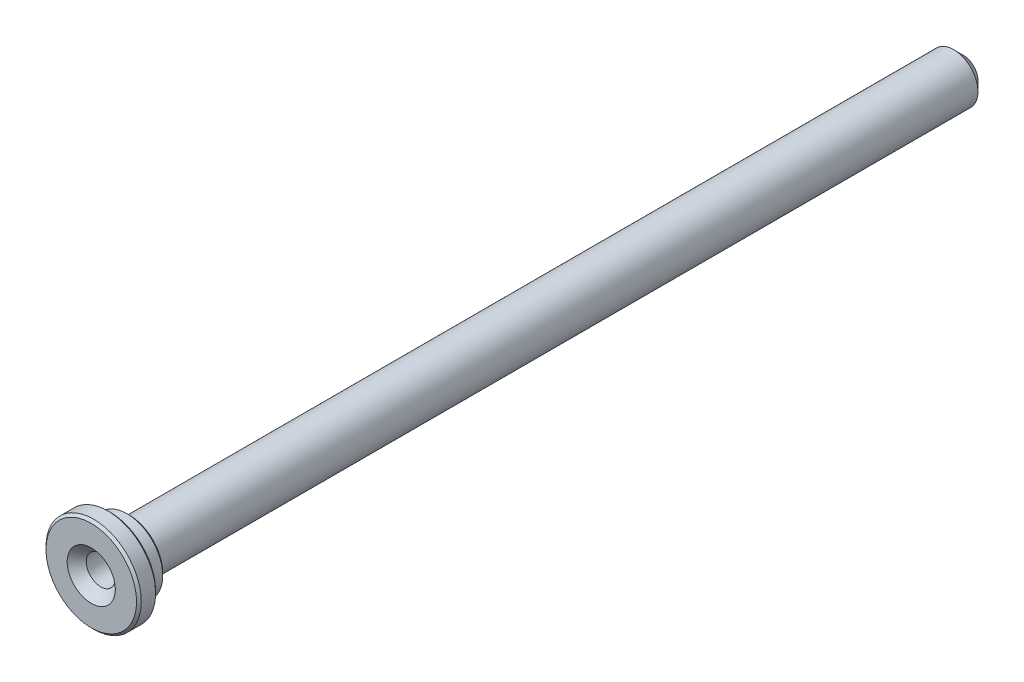
from build123d import *

# Parameters (mm, degrees)
CHAMFER_1_SIZE = 2
CHAMFER_2_SIZE = 0.5


with BuildPart() as part:
    # Эскиз1 → Повернуть1 (revolve)
    with BuildSketch(Plane(origin=(0, 0, 0), x_dir=(0, 0, -1), z_dir=(1, 0, 0)), mode=Mode.PRIVATE) as revolve_1_sk:
        Polygon((0, 0), (0, 5.1), (-175, 5.1), (-175, 7.5), (-179, 7.5), (-179, 10), (-183, 10), (-183, 3.05), (-143, 3.05), (-140.777028701, 0), align=None)
    revolve(revolve_1_sk.sketch.rotate(Axis((0, 0, 0), (0, 0, 1)), 90), axis=Axis((0, 0, 0), (0, 0, 1)))  # turned: the seam where the file's is

    # Фаска1
    chamfer_1_edges = [part.edges().sort_by_distance(p)[0] for p in [
        (5.1, 0, 0),
        (3.05, 0, 183),
    ]]
    chamfer(chamfer_1_edges, length=CHAMFER_1_SIZE)

    # Фаска2
    chamfer_2_edges = [part.edges().sort_by_distance(p)[0] for p in [
        (10, 0, 183),
        (10, 0, 179),
        (7.5, 0, 175),
    ]]
    chamfer(chamfer_2_edges, length=CHAMFER_2_SIZE)


solid = part.part
